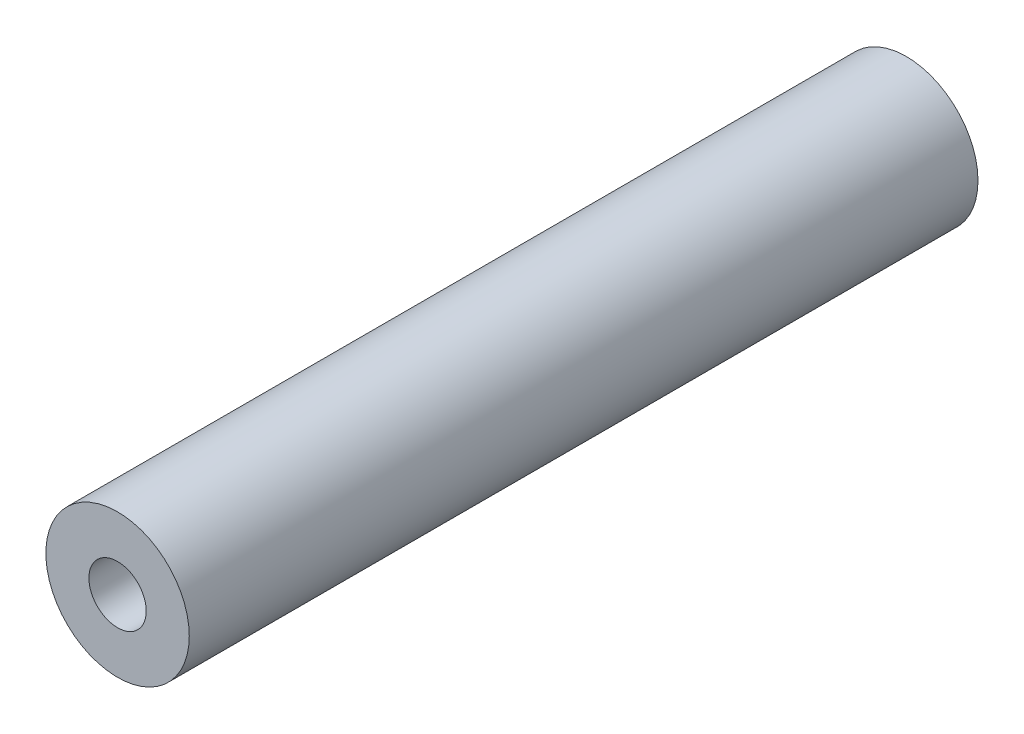
from build123d import *

# Parameters (mm, degrees)
SKETCH1_R           = 5
SKETCH1_R_2         = 2
BOSS_EXTRUDE1_DEPTH = 55


with BuildPart() as part:
    # Sketch1 → Boss-Extrude1 (new body)
    with BuildSketch(Plane.XY):
        with Locations((0, -65)):
            Circle(SKETCH1_R)
        with Locations((0, -65)):
            Circle(SKETCH1_R_2, mode=Mode.SUBTRACT)
    extrude(amount=BOSS_EXTRUDE1_DEPTH)


solid = part.part
